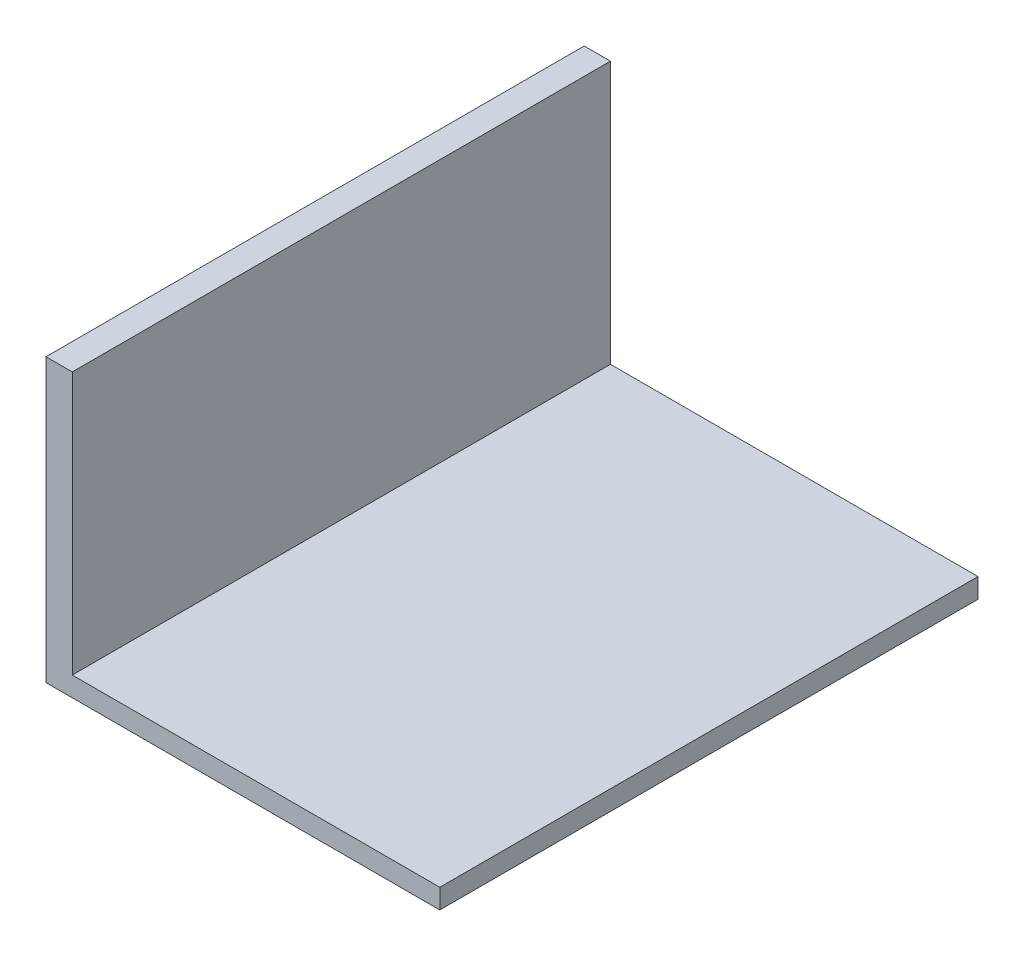
from build123d import *

# Parameters (mm, degrees)
SKETCH2_W           = 150
SKETCH2_H           = 205
BOSS_EXTRUDE1_DEPTH = 7.5
SKETCH3_W           = 10
SKETCH3_H           = 205
BOSS_EXTRUDE2_DEPTH = 100


with BuildPart() as part:
    # Sketch2 → Boss-Extrude1 (new body)
    with BuildSketch(Plane(origin=(0, 0, 0), x_dir=(1, 0, 0), z_dir=(0, 1, 0))):
        Rectangle(SKETCH2_W, SKETCH2_H)
    extrude(amount=BOSS_EXTRUDE1_DEPTH)

    # Sketch3 → Boss-Extrude2 (add)
    with BuildSketch(Plane(origin=(0, 7.5, 0), x_dir=(1, 0, 0), z_dir=(0, 1, 0))):
        with Locations((-70, 0)):
            Rectangle(SKETCH3_W, SKETCH3_H)
    extrude(amount=BOSS_EXTRUDE2_DEPTH)


solid = part.part
